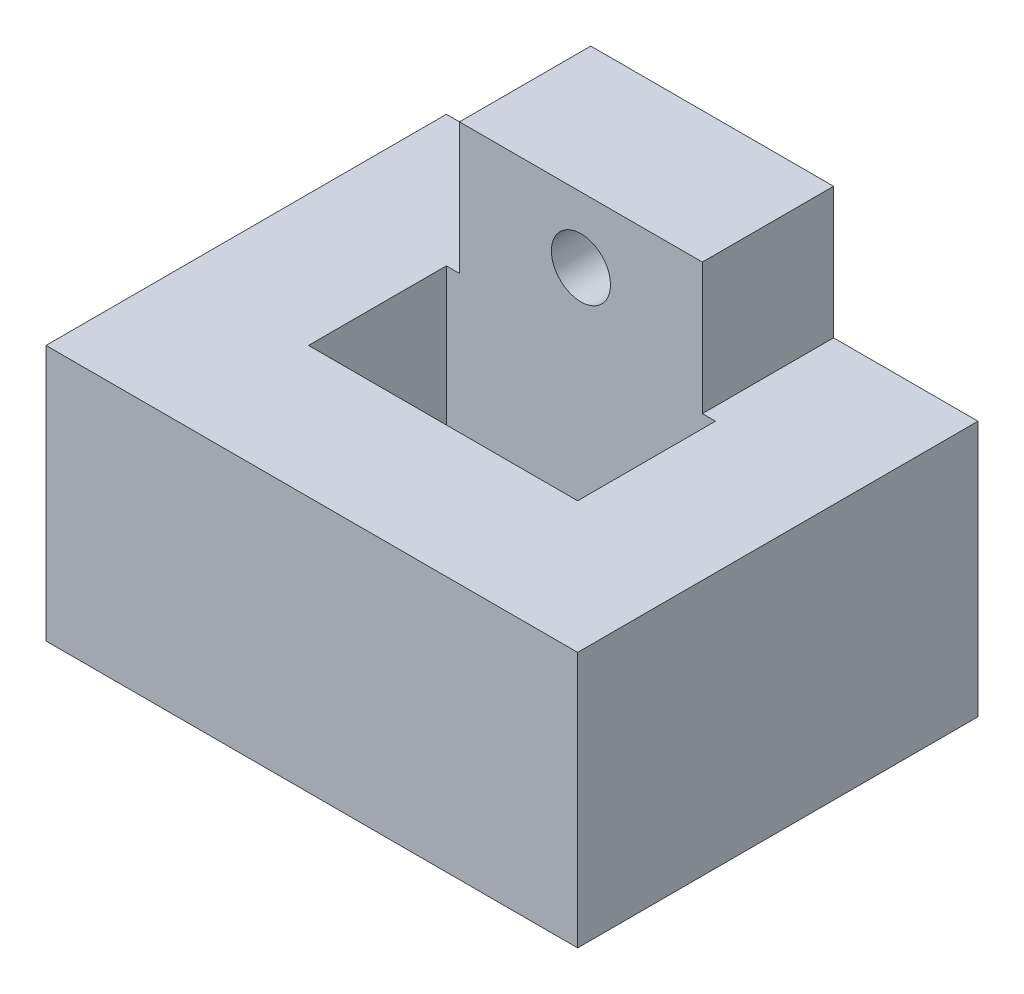
from build123d import *

# Parameters (mm, degrees)
SKETCH1_W           = 40.5
SKETCH1_H           = 30.5
SKETCH1_W_2         = 20.5
SKETCH1_H_2         = 10.5
BOSS_EXTRUDE1_DEPTH = 19.5
SKETCH4_R           = 1
BOSS_EXTRUDE2_DEPTH = 3
SKETCH3_W           = 18.5
SKETCH3_H           = 10
SKETCH3_R           = 2.25
BOSS_EXTRUDE3_DEPTH = 10


with BuildPart() as part:
    # Sketch1 → Boss-Extrude1 (new body)
    with BuildSketch(Plane(origin=(0, 0, 0), x_dir=(1, 0, 0), z_dir=(0, 1, 0))):
        Rectangle(SKETCH1_W, SKETCH1_H)
        Rectangle(SKETCH1_W_2, SKETCH1_H_2, mode=Mode.SUBTRACT)
    extrude(amount=BOSS_EXTRUDE1_DEPTH)

    # Sketch4 → Boss-Extrude2 (add)
    with BuildSketch(Plane.XY.offset(-15.25)):
        with Locations((0, 4.5)):
            Circle(SKETCH4_R)
    extrude(amount=-BOSS_EXTRUDE2_DEPTH)

    # Sketch3 → Boss-Extrude3 (add)
    with BuildSketch(Plane(origin=(0, 0, -15.25), x_dir=(-1, 0, 0), z_dir=(0, 0, -1))):
        with Locations((0, 24.5)):
            Rectangle(SKETCH3_W, SKETCH3_H)
        with Locations((0, 24.5)):
            Circle(SKETCH3_R, mode=Mode.SUBTRACT)
    extrude(amount=-BOSS_EXTRUDE3_DEPTH)


solid = part.part
